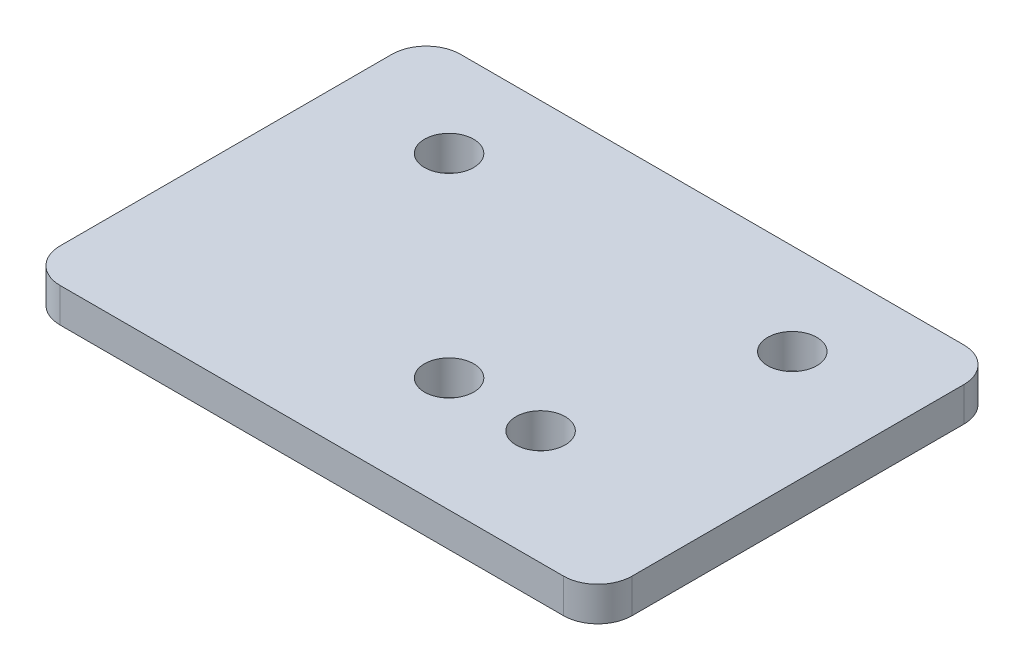
from build123d import *

# Parameters (mm, degrees)
SKETCH_1_W          = 50
SKETCH_1_H          = 35
EXTRUDE_1_DEPTH     = 3
SKETCH_2_R          = 2.15
CUT_EXTRUDE_1_DEPTH = 3
SKETCH_3_R          = 2.15
CUT_EXTRUDE_2_DEPTH = 3
FILLET_1_R          = 3


with BuildPart() as part:
    # 草图1 → 凸台-拉伸1 (new body)
    with BuildSketch(Plane(origin=(0, 0, 0), x_dir=(1, 0, 0), z_dir=(0, 1, 0))):
        Rectangle(SKETCH_1_W, SKETCH_1_H)
    extrude(amount=EXTRUDE_1_DEPTH)

    # 草图2 → 切除-拉伸1 (cut)
    with BuildSketch(Plane(origin=(0, 3, 0), x_dir=(1, 0, 0), z_dir=(0, 1, 0))):
        with Locations((-15, 9.5)):
            Circle(SKETCH_2_R)
        with Locations((15, 9.5)):
            Circle(SKETCH_2_R)
    extrude(amount=-CUT_EXTRUDE_1_DEPTH, mode=Mode.SUBTRACT)

    # 草图3 → 切除-拉伸2 (cut)
    with BuildSketch(Plane(origin=(0, 3, 0), x_dir=(1, 0, 0), z_dir=(0, 1, 0))):
        with Locations((2, -7.5)):
            Circle(SKETCH_3_R)
        with Locations((10, -7.5)):
            Circle(SKETCH_3_R)
    extrude(amount=-CUT_EXTRUDE_2_DEPTH, mode=Mode.SUBTRACT)

    # 圆角1
    fillet_1_edges = [part.edges().sort_by_distance(p)[0] for p in [
        (25, 1.5, 17.5),
        (-25, 1.5, 17.5),
        (-25, 1.5, -17.5),
        (25, 1.5, -17.5),
    ]]
    fillet(fillet_1_edges, radius=FILLET_1_R)


solid = part.part
